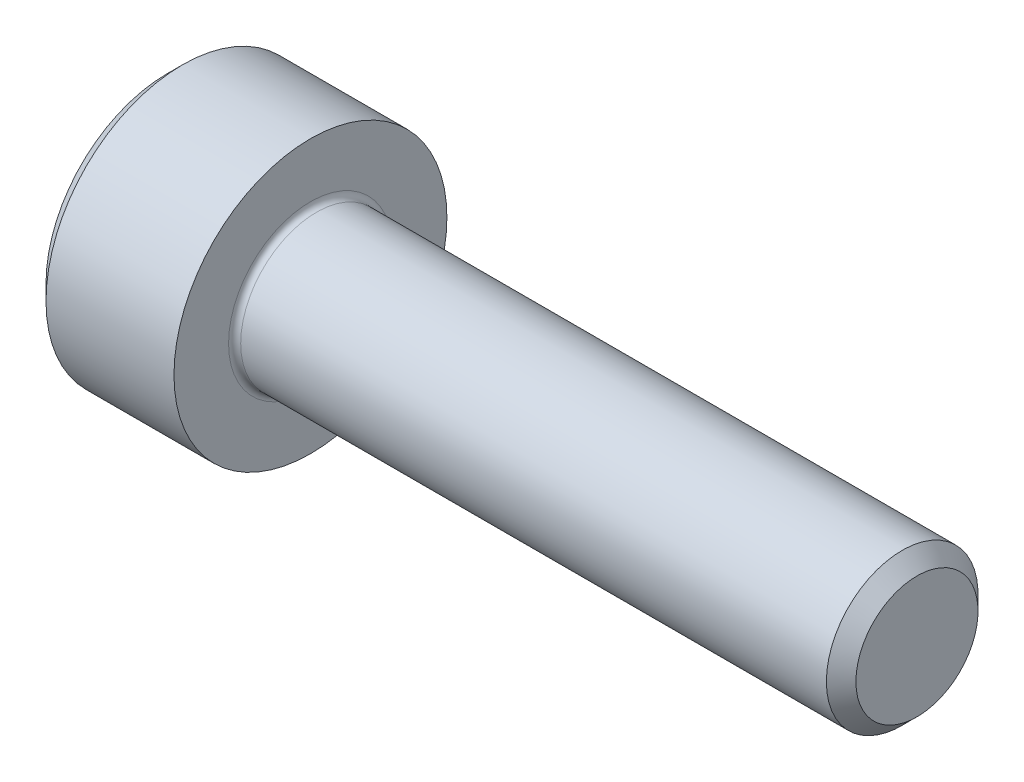
from build123d import *

# Parameters (mm, degrees)
CUT_EXTRUDE1_DEPTH = 1.1


with BuildPart() as part:
    # Sketch1 → Revolve1 (revolve)
    with BuildSketch(Plane.XY):
        with BuildLine():
            Line((-2.36, 0), (-2.36, 2))
            Line((-2.36, 2), (-2.11, 2.25))
            Line((-2.11, 2.25), (0, 2.25))
            Line((0, 2.25), (0, 1.35))
            ThreePointArc((0, 1.35), (0.029289322, 1.279289322), (0.1, 1.25))
            Line((0.1, 1.25), (9.7565, 1.25))
            Line((9.7565, 1.25), (10, 1.0065))
            Line((10, 1.0065), (10, 0))
            Line((10, 0), (-2.36, 0))
        make_face()
    revolve(axis=Axis((10, 0, 0), (-1, 0, 0)))

    # Sketch2 → Cut-Extrude1 (cut)
    with BuildSketch(Plane(origin=(-2.36, 0, 0), x_dir=(0, 0, -1), z_dir=(1, 0, 0))):
        Polygon((-1, 0.577350269), (-1, -0.577350269), (0, -1.154700538), (1, -0.577350269), (1, 0.577350269), (0, 1.154700538), align=None)
    extrude(amount=CUT_EXTRUDE1_DEPTH, mode=Mode.SUBTRACT)

    # Sketch3 → Cut-Revolve1 (revolve, cut)
    with BuildSketch(Plane.XY):
        Polygon((-1.26, 0), (-1.26, 1), (-0.682649731, 0), align=None)
    revolve(axis=Axis((-0.682649731, 0, 0), (-1, 0, 0)), mode=Mode.SUBTRACT)


solid = part.part
